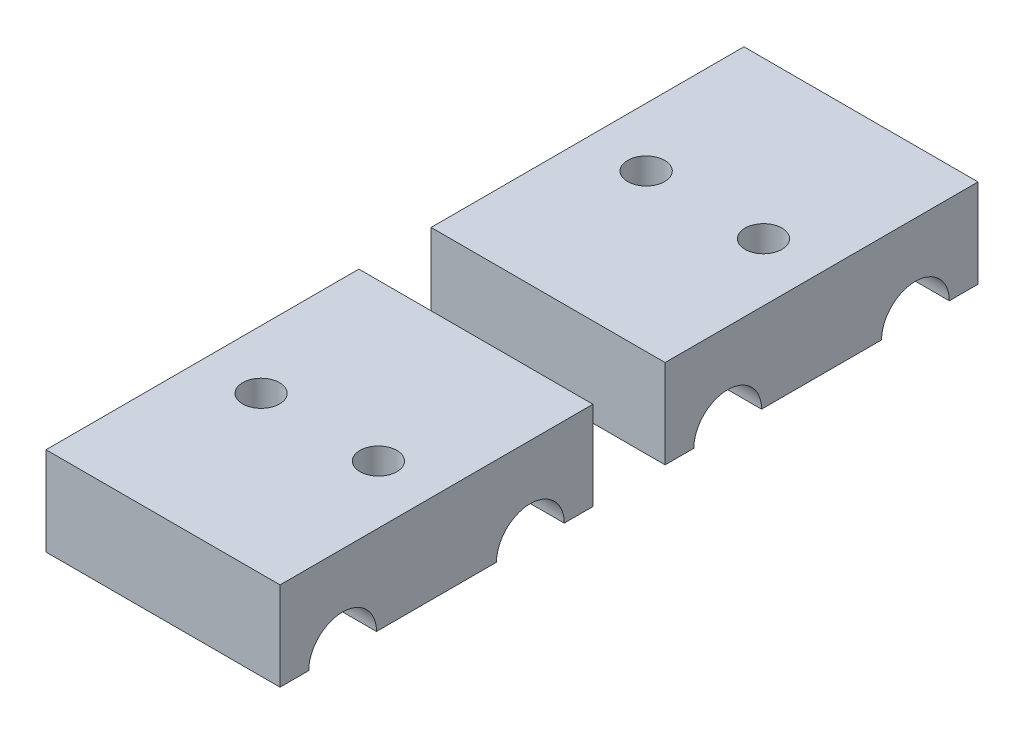
from build123d import *

# Parameters (mm, degrees)
REVOLVE1_ANGLE           = 180
BOSS_EXTRUDE1_DEPTH      = 9.25
BOSS_EXTRUDE1_DEPTH_BACK = 9.25
BOSS_EXTRUDE2_START      = 3.5
BOSS_EXTRUDE2_DEPTH      = 5.75
BOSS_EXTRUDE3_START      = -3.5
BOSS_EXTRUDE3_DEPTH      = 5.75
SKETCH13_W               = 5.5
SKETCH13_H               = 2.75
CUT_EXTRUDE9_DEPTH       = 1.75
SKETCH16_W               = 19
SKETCH16_H               = 4.169999961
CUT_EXTRUDE10_DEPTH      = 6
SKETCH17_W               = 19
SKETCH17_H               = 25.400000078
BOSS_EXTRUDE4_DEPTH      = 2.194999928
SKETCH18_R               = 1.5
CUT_EXTRUDE11_DEPTH      = 8.194999928


with BuildPart() as part:
    # Sketch6 → Revolve1 (revolve)
    with BuildSketch(Plane(origin=(0, 0, 0), x_dir=(1, 0, 0), z_dir=(0, 1, 0))):
        Polygon((0, 5), (0, 2.75), (8, 2.75), (8, 2.25), (9, 2.75), (15, 2.75), (15, 2.25), (16, 2.75), (19, 2.75), (19, 5), align=None)
    revolve(axis=Axis((0, 0, 0), (1, 0, 0)), revolution_arc=REVOLVE1_ANGLE)

    # Sketch9 → Boss-Extrude1 (add, two sides)
    with BuildSketch(Plane.XY) as boss_extrude1_sk:
        Polygon((0, 3.25), (0, 5), (19, 5), (19, 2.75), align=None)
    extrude(amount=BOSS_EXTRUDE1_DEPTH)
    extrude(boss_extrude1_sk.sketch, amount=-BOSS_EXTRUDE1_DEPTH_BACK)

    # Sketch9_3 → Boss-Extrude2 (add)
    with BuildSketch(Plane.XY.offset(BOSS_EXTRUDE2_START)):
        Polygon((0, 3.25), (19, 2.75), (19, 0), (0, 0), align=None)
    extrude(amount=BOSS_EXTRUDE2_DEPTH)

    # Sketch9_4 → Boss-Extrude3 (add)
    with BuildSketch(Plane.XY.offset(BOSS_EXTRUDE3_START)):
        Polygon((0, 3.25), (19, 2.75), (19, 0), (0, 0), align=None)
    extrude(amount=-BOSS_EXTRUDE3_DEPTH)

    # Sketch13 → Cut-Extrude9 (cut)
    with BuildSketch(Plane.ZY):
        with Locations((0, 1.375)):
            Rectangle(SKETCH13_W, SKETCH13_H)
    extrude(amount=-CUT_EXTRUDE9_DEPTH, mode=Mode.SUBTRACT)

    # Mirror4: part across plane


with BuildPart() as part_1:
    add(part.part)
    add(part.part.mirror(Plane.XY.offset(-7.62)))

    # Sketch16 → Cut-Extrude10 (cut, through all)
    with BuildSketch(Plane(origin=(0, 5, 0), x_dir=(1, 0, 0), z_dir=(0, 1, 0))):
        with Locations((9.5, 22.40500002)):
            Rectangle(SKETCH16_W, SKETCH16_H)
        with Locations((9.5, -7.16500002)):
            Rectangle(SKETCH16_W, SKETCH16_H)
    extrude(amount=-CUT_EXTRUDE10_DEPTH, mode=Mode.SUBTRACT)

    # Sketch17 → Boss-Extrude4 (add)
    with BuildSketch(Plane(origin=(0, 5, 0), x_dir=(1, 0, 0), z_dir=(0, 1, 0))):
        with Locations((9.5, 7.62)):
            Rectangle(SKETCH17_W, SKETCH17_H)
    extrude(amount=BOSS_EXTRUDE4_DEPTH)

    # Sketch18 → Cut-Extrude11 (cut, through all)
    with BuildSketch(Plane(origin=(0, 7.194999928, 0), x_dir=(1, 0, 0), z_dir=(0, 1, 0))):
        with Locations((14.2875, 7.619999961)):
            Circle(SKETCH18_R)
        with Locations((4.7625, 7.619999961)):
            Circle(SKETCH18_R)
    extrude(amount=-CUT_EXTRUDE11_DEPTH, mode=Mode.SUBTRACT)


with BuildPart() as body_2:
    # Mirror1: mirrored copy
    add(part_1.part.mirror(Plane(origin=(0, 0, -23.25), x_dir=(1, 0, 0), z_dir=(0, 0, -1))))


solid = Compound([part_1.part, body_2.part])
